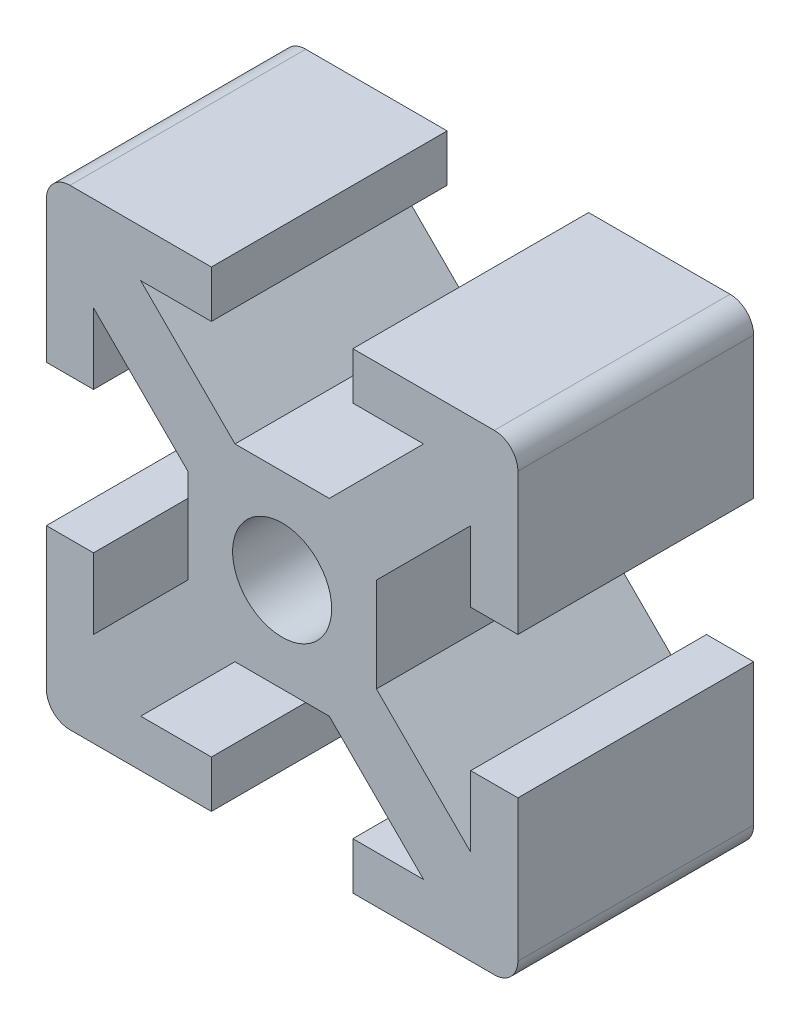
from build123d import *

# Parameters (mm, degrees)
SKETCH1_R           = 2.1
BOSS_EXTRUDE1_DEPTH = 10
FILLET1_R           = 1


with BuildPart() as part:
    # Sketch1 → Boss-Extrude1 (new body)
    with BuildSketch(Plane.XY):
        Polygon((3, 10), (3, 8), (6, 8), (2, 4), (-2, 4), (-6, 8), (-3, 8), (-3, 10), (-10, 10), (-10, 3), (-8, 3), (-8, 6), (-4, 2), (-4, -2), (-8, -6), (-8, -3), (-10, -3), (-10, -10), (-3, -10), (-3, -8), (-6, -8), (-2, -4), (2, -4), (6, -8), (3, -8), (3, -10), (10, -10), (10, -3), (8, -3), (8, -6), (4, -2), (4, 2), (8, 6), (8, 3), (10, 3), (10, 10), align=None)
        Circle(SKETCH1_R, mode=Mode.SUBTRACT)
    extrude(amount=BOSS_EXTRUDE1_DEPTH)

    # Fillet1
    fillet1_edges = [part.edges().sort_by_distance(p)[0] for p in [
        (-10, 10, 5),
        (10, 10, 5),
        (10, -10, 5),
        (-10, -10, 5),
    ]]
    fillet(fillet1_edges, radius=FILLET1_R)


solid = part.part
